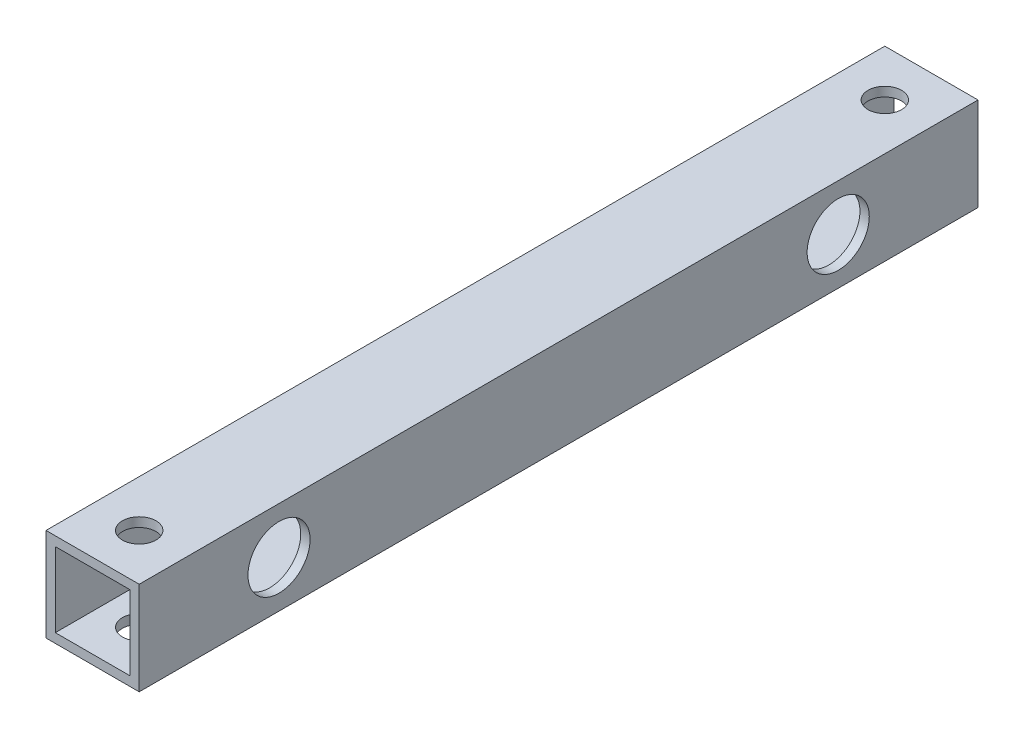
from build123d import *

# Parameters (mm, degrees)
SKETCH_1_W          = 15
SKETCH_1_H          = 15
SKETCH_1_W_2        = 12
SKETCH_1_H_2        = 12
EXTRUDE_1_DEPTH     = 135
SKETCH_2_R          = 2.7
CUT_EXTRUDE_1_DEPTH = 25
SKETCH_3_R          = 2.7
CUT_EXTRUDE_2_DEPTH = 25
SKETCH_5_R          = 5
CUT_EXTRUDE_4_DEPTH = 10


with BuildPart() as part:
    # ｽｹｯﾁ1 → ﾎﾞｽ - 押し出し1 (new body)
    with BuildSketch(Plane.XY):
        Rectangle(SKETCH_1_W, SKETCH_1_H)
        Rectangle(SKETCH_1_W_2, SKETCH_1_H_2, mode=Mode.SUBTRACT)
    extrude(amount=EXTRUDE_1_DEPTH)

    # ｽｹｯﾁ2 → ｶｯﾄ - 押し出し1 (cut)
    with BuildSketch(Plane(origin=(7.5, 0, 0), x_dir=(0, 0, -1), z_dir=(1, 0, 0))):
        with Locations((-112.5, 0)):
            Circle(SKETCH_2_R)
        with Locations((-22.5, 0)):
            Circle(SKETCH_2_R)
    extrude(amount=-CUT_EXTRUDE_1_DEPTH, mode=Mode.SUBTRACT)

    # ｽｹｯﾁ3 → ｶｯﾄ - 押し出し2 (cut)
    with BuildSketch(Plane(origin=(0, 7.5, 0), x_dir=(1, 0, 0), z_dir=(0, 1, 0))):
        with Locations((0, -7.5)):
            Circle(SKETCH_3_R)
        with Locations((0, -127.5)):
            Circle(SKETCH_3_R)
    extrude(amount=-CUT_EXTRUDE_2_DEPTH, mode=Mode.SUBTRACT)

    # ｽｹｯﾁ5 → ｶｯﾄ - 押し出し4 (cut)
    with BuildSketch(Plane(origin=(7.5, 0, 0), x_dir=(0, 0, -1), z_dir=(1, 0, 0))):
        with Locations((-22.5, 0)):
            Circle(SKETCH_5_R)
        with Locations((-112.5, 0)):
            Circle(SKETCH_5_R)
    extrude(amount=-CUT_EXTRUDE_4_DEPTH, mode=Mode.SUBTRACT)


solid = part.part
